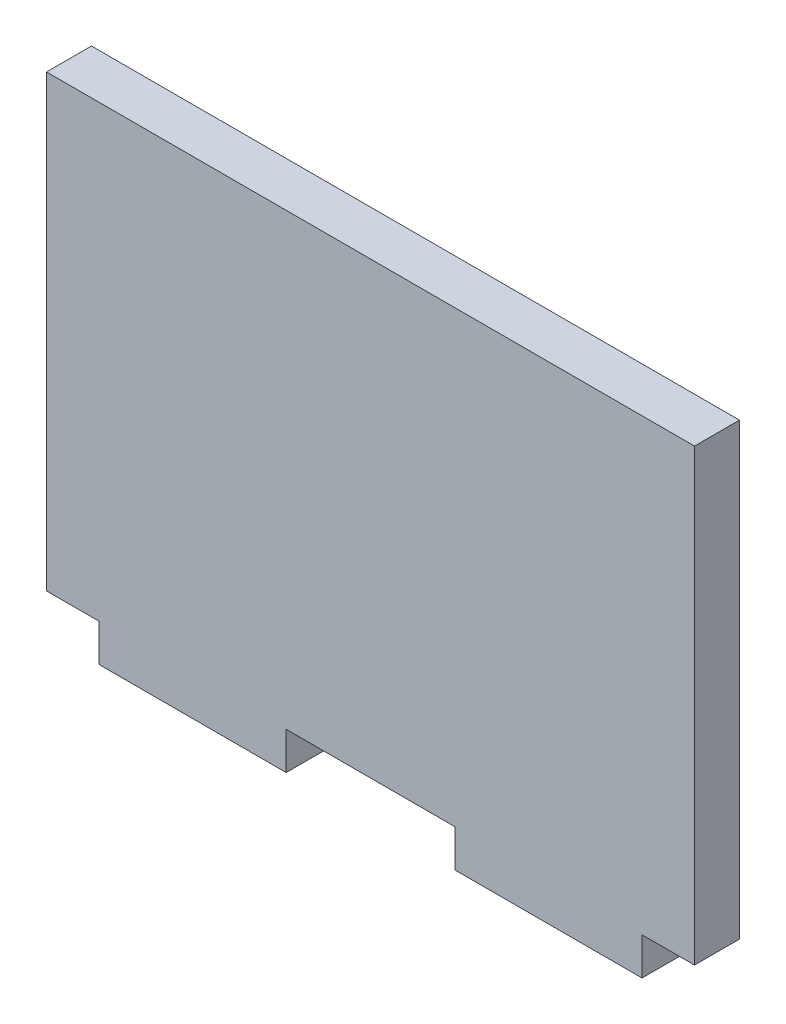
from build123d import *

# Parameters (mm, degrees)
ESQUISSE1_W        = 86.5
ESQUISSE1_H        = 60
ESQUISSE1_W_2      = 24.98
ESQUISSE1_H_2      = 5
BOSS_EXTRU_1_DEPTH = 6


with BuildPart() as part:
    # Esquisse1 → Boss.-Extru.1 (new body)
    with BuildSketch(Plane.XY):
        with Locations((16.736924874, 25.769230769)):
            Rectangle(ESQUISSE1_W, ESQUISSE1_H)
        with Locations((-7.013075126, -6.730769231)):
            Rectangle(ESQUISSE1_W_2, ESQUISSE1_H_2)
        with Locations((40.486924874, -6.730769231)):
            Rectangle(ESQUISSE1_W_2, ESQUISSE1_H_2)
    extrude(amount=BOSS_EXTRU_1_DEPTH)


solid = part.part
